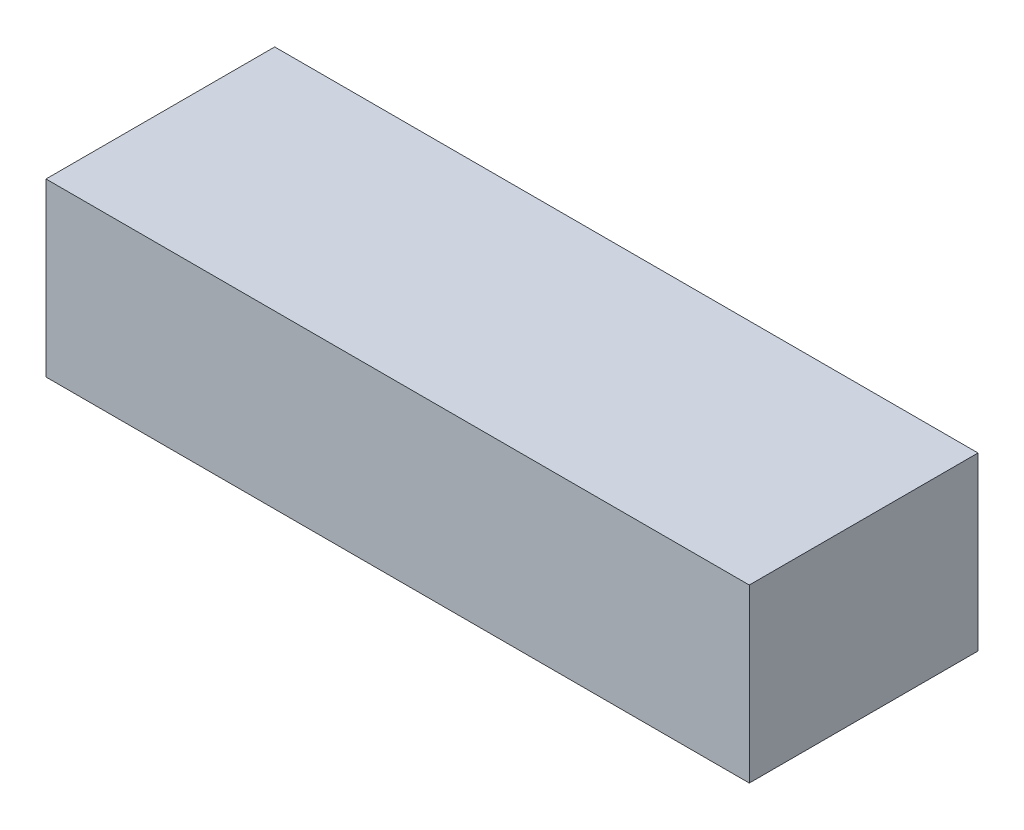
from build123d import *

# Parameters (mm, degrees)
SZKIC1_W                    = 123
SZKIC1_H                    = 30
DODANIE_WYCI_GNI_CIE1_DEPTH = 40


with BuildPart() as part:
    # Szkic1 → Dodanie-wyciągnięcie1 (new body)
    with BuildSketch(Plane.XY):
        with Locations((61.5, 15)):
            Rectangle(SZKIC1_W, SZKIC1_H)
    extrude(amount=DODANIE_WYCI_GNI_CIE1_DEPTH)


solid = part.part
